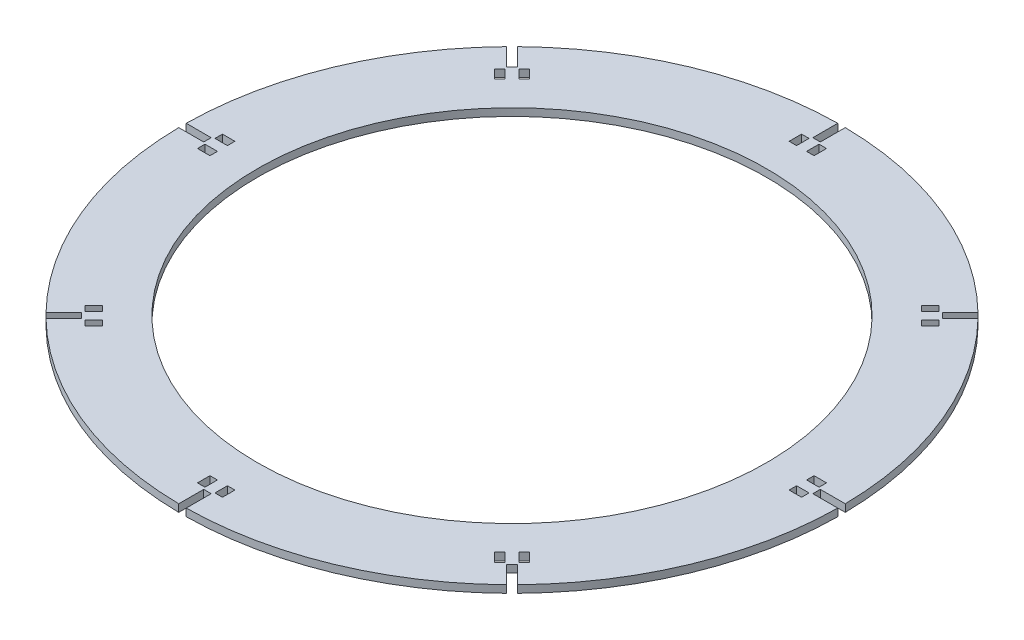
from build123d import *

# Parameters (mm, degrees)
SKETCH1_R           = 132.01
BOSS_EXTRUDE1_DEPTH = 3
CUT_EXTRUDE1_START  = -3
CUT_EXTRUDE1_DEPTH  = 4
CIRPATTERN1_COUNT   = 8
SKETCH7_W           = 3
SKETCH7_H           = 5
CUT_EXTRUDE4_DEPTH  = 3
CIRPATTERN2_COUNT   = 8
SKETCH8_R           = 102.01
CUT_EXTRUDE6_DEPTH  = 10


with BuildPart() as part:
    # Sketch1 → Boss-Extrude1 (new body)
    with BuildSketch(Plane(origin=(0, 0, 0), x_dir=(1, 0, 0), z_dir=(0, 1, 0))):
        Circle(SKETCH1_R)
    extrude(amount=BOSS_EXTRUDE1_DEPTH)

    # Sketch2 → Cut-Extrude1 (cut)
    with BuildSketch(Plane(origin=(0, 3, 0), x_dir=(1, 0, 0), z_dir=(0, 1, 0)).offset(CUT_EXTRUDE1_START)):
        Polygon((-1.5, 733.700659415), (-1.5, 132.001477643), (-1.5, 122.001477643), (1.5, 122.001477643), (1.5, 132.001477643), (1.5, 733.700659415), (1.5, 1937.099022959), (-1.5, 1937.099022959), align=None)
    cut_extrude1 = extrude(amount=CUT_EXTRUDE1_DEPTH, mode=Mode.SUBTRACT)

    # CirPattern1: Cut-Extrude1 ×8 about axis
    cirpattern1_axis = Axis((0, 0, 0), (0, -1, 0))
    for i in range(1, CIRPATTERN1_COUNT):
        add(cut_extrude1.rotate(cirpattern1_axis, i * 360 / CIRPATTERN1_COUNT), mode=Mode.SUBTRACT)

    # Sketch7 → Cut-Extrude4 (cut)
    with BuildSketch(Plane(origin=(0, 3, 0), x_dir=(1, 0, 0), z_dir=(0, 1, 0))):
        with Locations((-3.5, 118.501477643)):
            Rectangle(SKETCH7_W, SKETCH7_H)
        with Locations((3.5, 118.501477643)):
            Rectangle(SKETCH7_W, SKETCH7_H)
    cut_extrude4 = extrude(amount=-CUT_EXTRUDE4_DEPTH, mode=Mode.SUBTRACT)

    # CirPattern2: Cut-Extrude4 ×8 about axis
    cirpattern2_axis = Axis((0, 0, 0), (0, 1, 0))
    for i in range(1, CIRPATTERN2_COUNT):
        add(cut_extrude4.rotate(cirpattern2_axis, i * 360 / CIRPATTERN2_COUNT), mode=Mode.SUBTRACT)

    # Sketch8 → Cut-Extrude6 (cut)
    with BuildSketch(Plane(origin=(0, 3, 0), x_dir=(1, 0, 0), z_dir=(0, 1, 0))):
        Circle(SKETCH8_R)
    extrude(amount=-CUT_EXTRUDE6_DEPTH, mode=Mode.SUBTRACT)


solid = part.part
